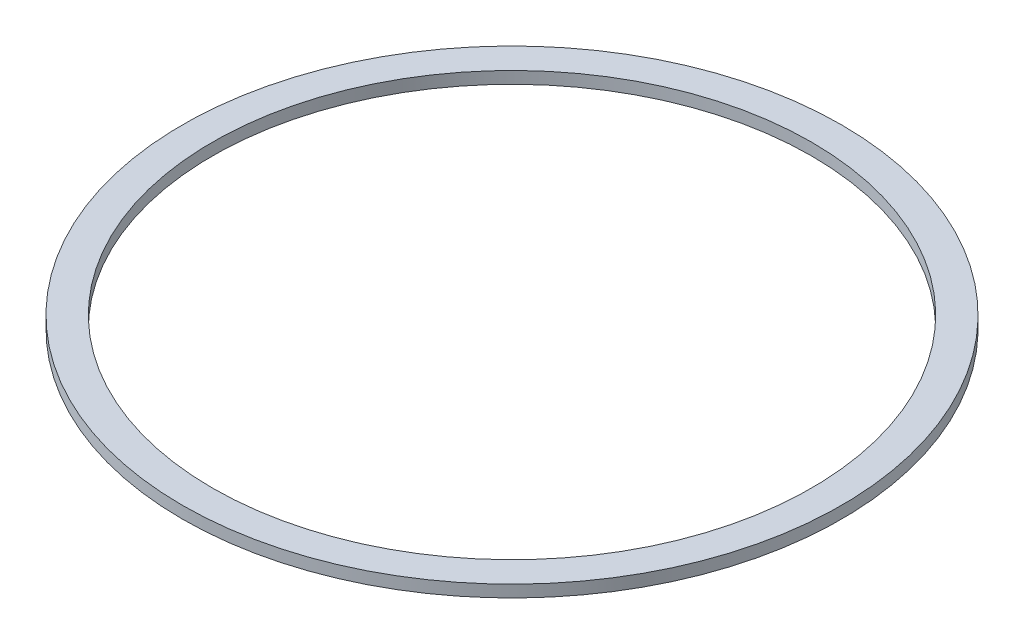
from build123d import *

# Parameters (mm, degrees)
SKETCH1_R           = 82.5
SKETCH1_R_2         = 75
BOSS_EXTRUDE1_DEPTH = 3


with BuildPart() as part:
    # Sketch1 → Boss-Extrude1 (new body)
    with BuildSketch(Plane(origin=(0, 0, 0), x_dir=(1, 0, 0), z_dir=(0, 1, 0))):
        Circle(SKETCH1_R)
        Circle(SKETCH1_R_2, mode=Mode.SUBTRACT)
    extrude(amount=BOSS_EXTRUDE1_DEPTH)


solid = part.part
